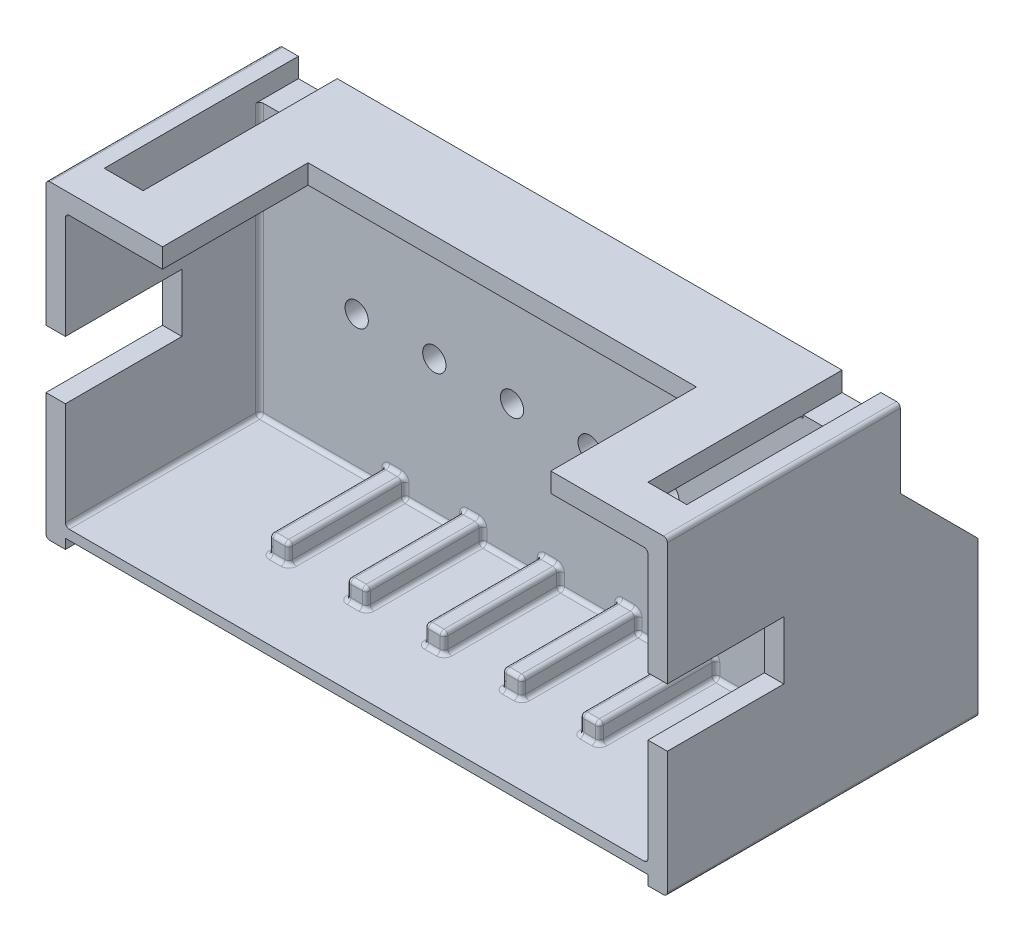
from build123d import *

# Parameters (mm, degrees)
SKETCH1_W           = 16
SKETCH1_H           = 8
SKETCH1_R           = 0.3
BOSS_EXTRUDE1_DEPTH = 8
SKETCH2_W           = 15
SKETCH2_H           = 7
CUT_EXTRUDE1_DEPTH  = 5
SKETCH4_W           = 15
SKETCH4_H           = 2
CUT_EXTRUDE2_DEPTH  = 9
CUT_EXTRUDE3_DEPTH  = 17
CUT_EXTRUDE4_REACH  = 10
SKETCH6_W           = 10
SKETCH6_H           = 3.749204525
SKETCH7_W           = 1
SKETCH7_H           = 5
CUT_EXTRUDE5_DEPTH  = 0.5
SKETCH8_W           = 0.5
SKETCH8_H           = 3
BOSS_EXTRUDE2_DEPTH = 0.5
SKETCH9_W           = 3
SKETCH9_H           = 1.5
CUT_EXTRUDE6_DEPTH  = 17
SKETCH10_W          = 15
SKETCH10_H          = 0.25
CUT_EXTRUDE7_DEPTH  = 9
FILLET1_R           = 0.1


with BuildPart() as part:
    # Sketch1 → Boss-Extrude1 (new body)
    with BuildSketch(Plane.XY):
        with Locations((8, 4)):
            Rectangle(SKETCH1_W, SKETCH1_H)
        with Locations((3, 4)):
            Circle(SKETCH1_R, mode=Mode.SUBTRACT)
        with Locations((5, 4)):
            Circle(SKETCH1_R, mode=Mode.SUBTRACT)
        with Locations((7, 4)):
            Circle(SKETCH1_R, mode=Mode.SUBTRACT)
        with Locations((9, 4)):
            Circle(SKETCH1_R, mode=Mode.SUBTRACT)
        with Locations((11, 4)):
            Circle(SKETCH1_R, mode=Mode.SUBTRACT)
        with Locations((13, 4)):
            Circle(SKETCH1_R, mode=Mode.SUBTRACT)
    extrude(amount=BOSS_EXTRUDE1_DEPTH)

    # Sketch2 → Cut-Extrude1 (cut)
    with BuildSketch(Plane.XY.offset(8)):
        with Locations((8, 4)):
            Rectangle(SKETCH2_W, SKETCH2_H)
    extrude(amount=-CUT_EXTRUDE1_DEPTH, mode=Mode.SUBTRACT)

    # Sketch4 → Cut-Extrude2 (cut, through all)
    with BuildSketch(Plane(origin=(0, 8, 0), x_dir=(1, 0, 0), z_dir=(0, 1, 0))):
        with Locations((8, -1)):
            Rectangle(SKETCH4_W, SKETCH4_H)
    extrude(amount=-CUT_EXTRUDE2_DEPTH, mode=Mode.SUBTRACT)

    # Sketch5 → Cut-Extrude3 (cut, through all)
    with BuildSketch(Plane(origin=(16, 0, 0), x_dir=(0, 0, -1), z_dir=(1, 0, 0))):
        Polygon((-2, 8), (0, 8), (0, 4), (-2, 6), align=None)
    extrude(amount=-CUT_EXTRUDE3_DEPTH, mode=Mode.SUBTRACT)

    # Sketch6 → Cut-Extrude4 (cut, up to next)
    with BuildSketch(Plane(origin=(0, 8, 0), x_dir=(1, 0, 0), z_dir=(0, 1, 0)), mode=Mode.PRIVATE) as cut_extrude4_sk1:
        with Locations((8, -6.125397738)):
            Rectangle(SKETCH6_W, SKETCH6_H)
    cut_extrude4_tool1 = extrude(cut_extrude4_sk1.sketch, amount=-CUT_EXTRUDE4_REACH, mode=Mode.PRIVATE) & part.part
    add(cut_extrude4_tool1.solids().sort_by_distance((8, 8, 6.125398))[0], mode=Mode.SUBTRACT)

    # Sketch7 → Cut-Extrude5 (cut)
    with BuildSketch(Plane(origin=(0, 8, 0), x_dir=(1, 0, 0), z_dir=(0, 1, 0))):
        with Locations((1, -4.5)):
            Rectangle(SKETCH7_W, SKETCH7_H)
        with Locations((15, -4.5)):
            Rectangle(SKETCH7_W, SKETCH7_H)
    extrude(amount=-CUT_EXTRUDE5_DEPTH, mode=Mode.SUBTRACT)

    # Sketch8 → Boss-Extrude2 (add)
    with BuildSketch(Plane(origin=(0, 0.5, 0), x_dir=(1, 0, 0), z_dir=(0, 1, 0))):
        with Locations((4, -4.5)):
            Rectangle(SKETCH8_W, SKETCH8_H)
        with Locations((6, -4.5)):
            Rectangle(SKETCH8_W, SKETCH8_H)
        with Locations((8, -4.5)):
            Rectangle(SKETCH8_W, SKETCH8_H)
        with Locations((10, -4.5)):
            Rectangle(SKETCH8_W, SKETCH8_H)
        with Locations((12, -4.5)):
            Rectangle(SKETCH8_W, SKETCH8_H)
    extrude(amount=BOSS_EXTRUDE2_DEPTH)

    # Sketch9 → Cut-Extrude6 (cut, through all)
    with BuildSketch(Plane(origin=(16, 0, 0), x_dir=(0, 0, -1), z_dir=(1, 0, 0))):
        with Locations((-6.5, 4)):
            Rectangle(SKETCH9_W, SKETCH9_H)
    extrude(amount=-CUT_EXTRUDE6_DEPTH, mode=Mode.SUBTRACT)

    # Sketch10 → Cut-Extrude7 (cut, through all)
    with BuildSketch(Plane.XY.offset(8)):
        with Locations((8, 0.125)):
            Rectangle(SKETCH10_W, SKETCH10_H)
    extrude(amount=-CUT_EXTRUDE7_DEPTH, mode=Mode.SUBTRACT)

    # Fillet1
    fillet1_edges = [part.edges().sort_by_distance(p)[0] for p in [
        (4.25, 0.75, 3),
        (3.75, 0.75, 3),
        (3.75, 0.5, 4.5),
        (4.25, 0.5, 4.5),
        (5.75, 0.5, 4.5),
        (6.25, 0.5, 4.5),
        (11.75, 0.5, 4.5),
        (12.25, 0.5, 4.5),
        (9.75, 0.5, 4.5),
        (10.25, 0.5, 4.5),
        (7.75, 0.5, 4.5),
        (8.25, 0.5, 4.5),
        (6.25, 0.75, 3),
        (5.75, 0.75, 3),
        (8.25, 0.75, 3),
        (7.75, 0.75, 3),
        (10.25, 0.75, 3),
        (9.75, 0.75, 3),
        (12.25, 0.75, 3),
        (11.75, 0.75, 3),
        (4.25, 1, 4.5),
        (3.75, 1, 4.5),
        (4, 1, 3),
        (3.75, 0.75, 6),
        (4, 1, 6),
        (4.25, 0.75, 6),
        (4, 0.5, 6),
        (5.75, 0.75, 6),
        (6.25, 0.75, 6),
        (6, 0.5, 6),
        (11.75, 0.75, 6),
        (12.25, 0.75, 6),
        (12, 0.5, 6),
        (9.75, 0.75, 6),
        (10.25, 0.75, 6),
        (10, 0.5, 6),
        (7.75, 0.75, 6),
        (8.25, 0.75, 6),
        (8, 0.5, 6),
        (6.25, 1, 4.5),
        (6, 1, 6),
        (5.75, 1, 4.5),
        (6, 1, 3),
        (8.25, 1, 4.5),
        (8, 1, 6),
        (7.75, 1, 4.5),
        (8, 1, 3),
        (10.25, 1, 4.5),
        (10, 1, 6),
        (9.75, 1, 4.5),
        (10, 1, 3),
        (12.25, 1, 4.5),
        (12, 1, 6),
        (11.75, 1, 4.5),
        (12, 1, 3),
        (11, 0.5, 3),
        (9, 0.5, 3),
        (7, 0.5, 3),
        (13.875, 0.5, 3),
        (15.5, 4, 3),
        (8, 7.5, 3),
        (0.5, 7.5, 7.5),
        (0.5, 4, 3),
        (5, 0.5, 3),
        (2.125, 0.5, 3),
        (0.5, 0.5, 5.5),
        (0, 0, 4),
        (16, 0, 4),
        (16, 8, 5),
        (0, 8, 5),
        (15.5, 7.5, 7.5),
        (15.75, 4, 0),
        (15.75, 6, 2),
        (0.25, 6, 2),
        (0.25, 4, 0),
        (15.5, 0.5, 5.5),
    ]]
    fillet(fillet1_edges, radius=FILLET1_R)


solid = part.part
